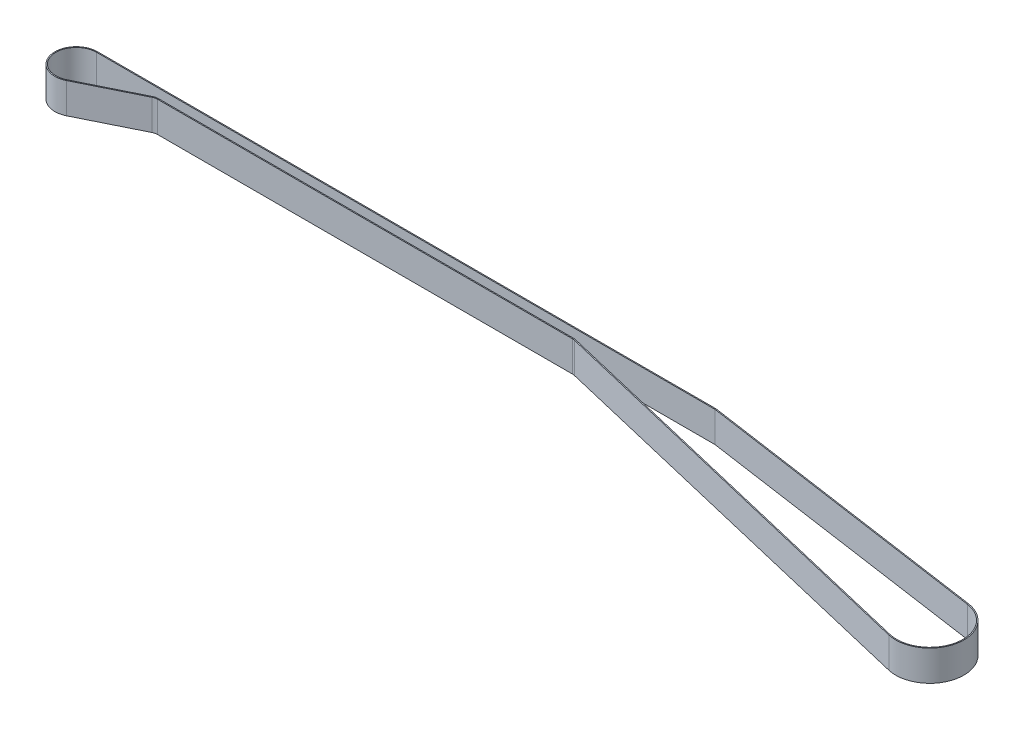
from build123d import *

# Parameters (mm, degrees)
BOSS_EXTRUDE1_DEPTH = 15


with BuildPart() as part:
    # Sketch2 → Boss-Extrude1 (new body)
    with BuildSketch(Plane(origin=(0, 0, 0), x_dir=(1, 0, 0), z_dir=(0, 1, 0))):
        with BuildLine():
            Line((0, 10.5), (303.9759017, 10.5))
            Line((303.9759017, 10.5), (448.913075843, -10.421830981))
            ThreePointArc((448.913075843, -10.421830981), (462.973791064, -30.136121747), (442.647176825, -43.296126554))
            Line((442.647176825, -43.296126554), (239.996066619, 4.864515389))
            ThreePointArc((239.996066619, 4.864515389), (239.421989284, 4.966013338), (238.84, 5))
            Line((238.84, 5), (35, 5))
            ThreePointArc((35, 5), (33.863075353, 4.869024784), (32.785714286, 4.482960938))
            Line((32.785714286, 4.482960938), (4.65, -9.414217971))
            ThreePointArc((4.65, -9.414217971), (-10.224952046, -2.38754176), (0, 10.5))
        make_face()
        with BuildLine():
            Line((0, 10), (303.94, 10))
            Line((303.94, 10), (448.841640743, -10.916701698))
            ThreePointArc((448.841640743, -10.916701698), (462.482633122, -30.042506173), (442.762783487, -42.809675015))
            Line((442.762783487, -42.809675015), (240.111673281, 5.350966928))
            ThreePointArc((240.111673281, 5.350966928), (239.480188213, 5.462614672), (238.84, 5.5))
            Line((238.84, 5.5), (35, 5.5))
            ThreePointArc((35, 5.5), (33.749382888, 5.355927262), (32.564285714, 4.931257032))
            Line((32.564285714, 4.931257032), (4.428571429, -8.965921877))
            ThreePointArc((4.428571429, -8.965921877), (-9.738049568, -2.273849295), (0, 10))
        make_face(mode=Mode.SUBTRACT)
    extrude(amount=BOSS_EXTRUDE1_DEPTH)


solid = part.part
